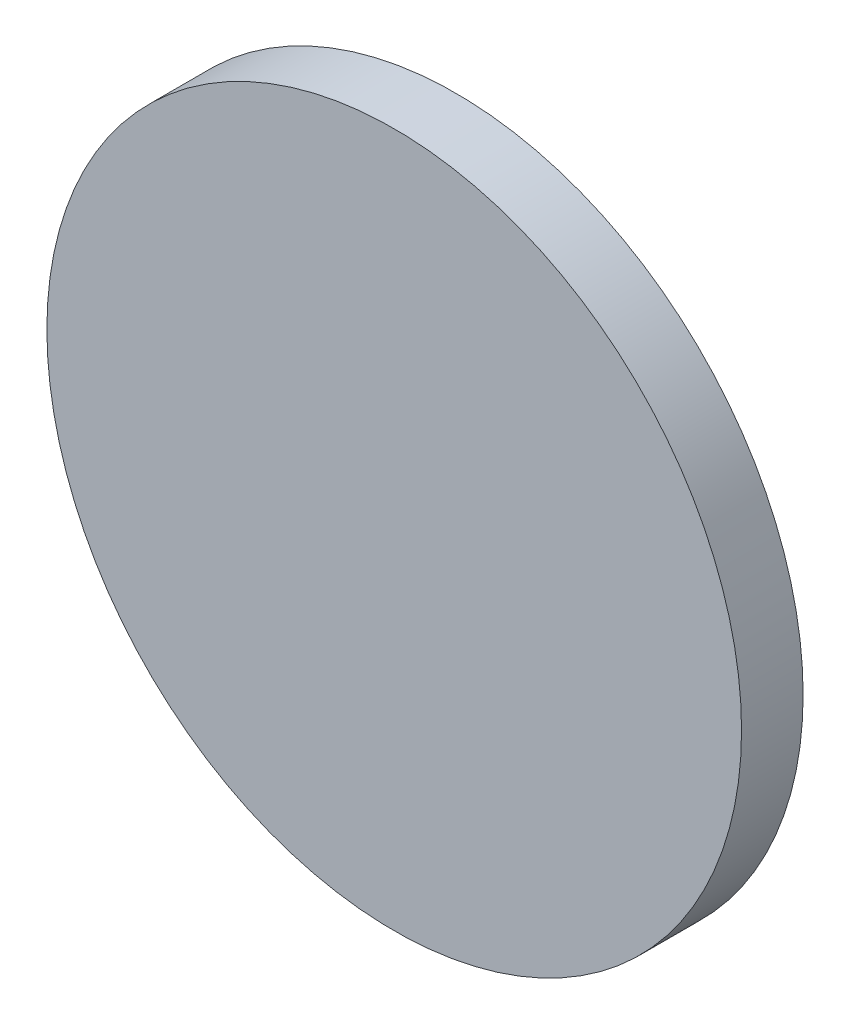
from build123d import *

# Parameters (mm, degrees)
SKETCH1_R           = 14.327338822
BOSS_EXTRUDE1_DEPTH = 2.54


with BuildPart() as part:
    # Sketch1 → Boss-Extrude1 (new body)
    with BuildSketch(Plane.XY):
        Circle(SKETCH1_R)
    extrude(amount=BOSS_EXTRUDE1_DEPTH)


solid = part.part
